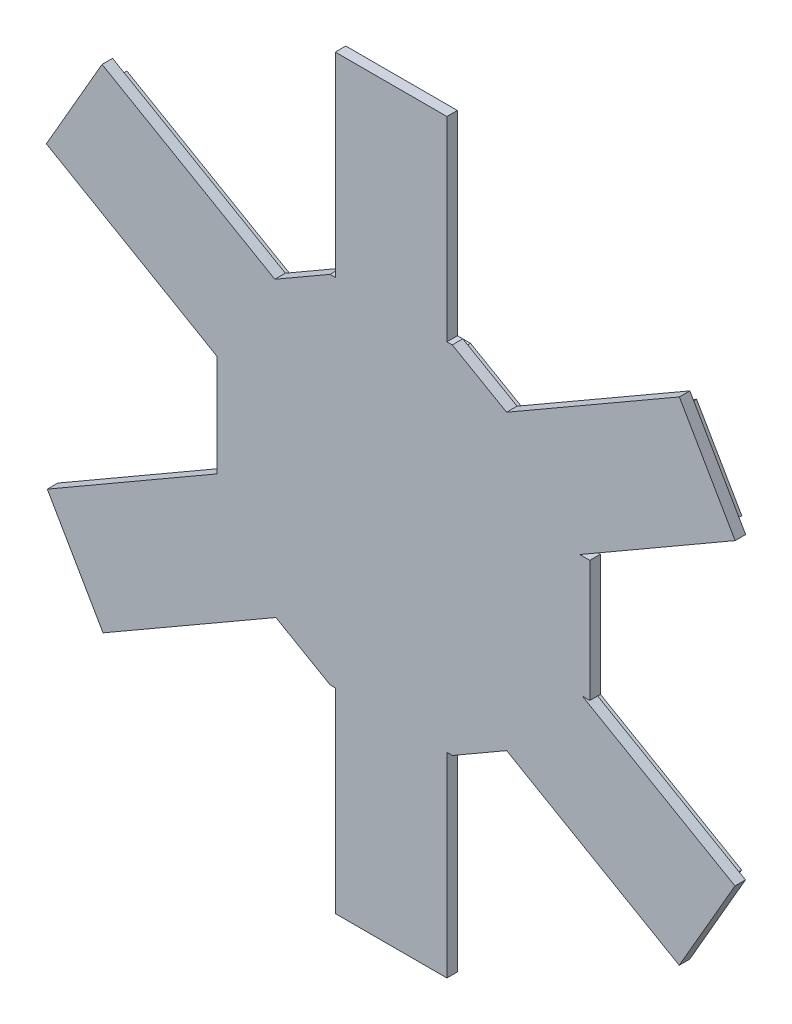
from build123d import *

# Parameters (mm, degrees)
AUFSATZ_LINEAR_AUSTRAGEN1_DEPTH = 2
AUFSATZ_LINEAR_AUSTRAGEN2_DEPTH = 2


with BuildPart() as part:
    # Skizze1 → Aufsatz-Linear austragen1 (new body)
    with BuildSketch(Plane.XY.offset(14.58852)):
        Polygon((-22.149859894, 27.765281808), (-55.023633975, 46.732102334), (-65.619428736, 28.349034811), (-33.1799992, 9.582671858), (-33.1799992, -9.82193495), (-65.441180026, -28.458395245), (-54.832668225, -46.841377939), (-21.94526311, -27.869445957), (-11.635211495, -33.81000048), (-10.63000112, -33.81000048), (-10.63000112, -70.99999976), (10.588764643, -70.99999976), (10.608764603, -33.81000048), (11.636228403, -33.81000048), (21.961456264, -27.849347945), (54.791716349, -46.801638497), (65.402118422, -28.428154068), (36.372671479, -11.66999904), (37.79000014, -11.66999904), (37.79000014, 11.41999954), (35.875483821, 11.41999954), (65.431940836, 28.488460753), (54.822266278, 46.860690996), (21.946878227, 27.90320319), (11.612735063, 33.83000044), (10.5900012, 33.83000044), (10.5900012, 70.94999986), (-10.65000108, 70.94999986), (-10.65000108, 33.83000044), (-11.635793215, 33.83000044), align=None)
    extrude(amount=AUFSATZ_LINEAR_AUSTRAGEN1_DEPTH)

    # Skizze2 → Aufsatz-Linear austragen2 (add)
    with BuildSketch(Plane(origin=(0, 0, 14.58852), x_dir=(-1, 0, 0), z_dir=(0, 0, -1))):
        Polygon((29.5799992, 9.810611271), (29.5799992, -10.052032223), (62.709719012, -29.19022531), (54.099914325, -44.109744044), (21.94585632, -25.560861902), (11.100245691, -31.81000048), (8.63000112, -31.81000048), (8.63000112, -68.99999976), (-8.58983991, -68.99999976), (-8.60983987, -31.81000048), (-11.100378331, -31.81000048), (-21.96144846, -25.540011472), (-54.059788028, -44.0697781), (-62.669841481, -29.160193905), (-28.907796867, -9.66999904), (-11.412909471, -9.66999904), (-11.412909471, 9.41999954), (-28.412909471, 9.41999954), (-62.699818266, 29.220233802), (-54.089861915, 44.129654408), (-21.949592186, 25.596070242), (-11.079922713, 31.83000044), (-8.5900012, 31.83000044), (-8.5900012, 68.94999986), (8.65000108, 68.94999986), (8.65000108, 31.83000044), (11.100321567, 31.83000044), (22.149980751, 25.45634161), (54.290039962, 43.999838722), (62.88949027, 29.080308923), align=None)
    extrude(amount=AUFSATZ_LINEAR_AUSTRAGEN2_DEPTH)


solid = part.part
